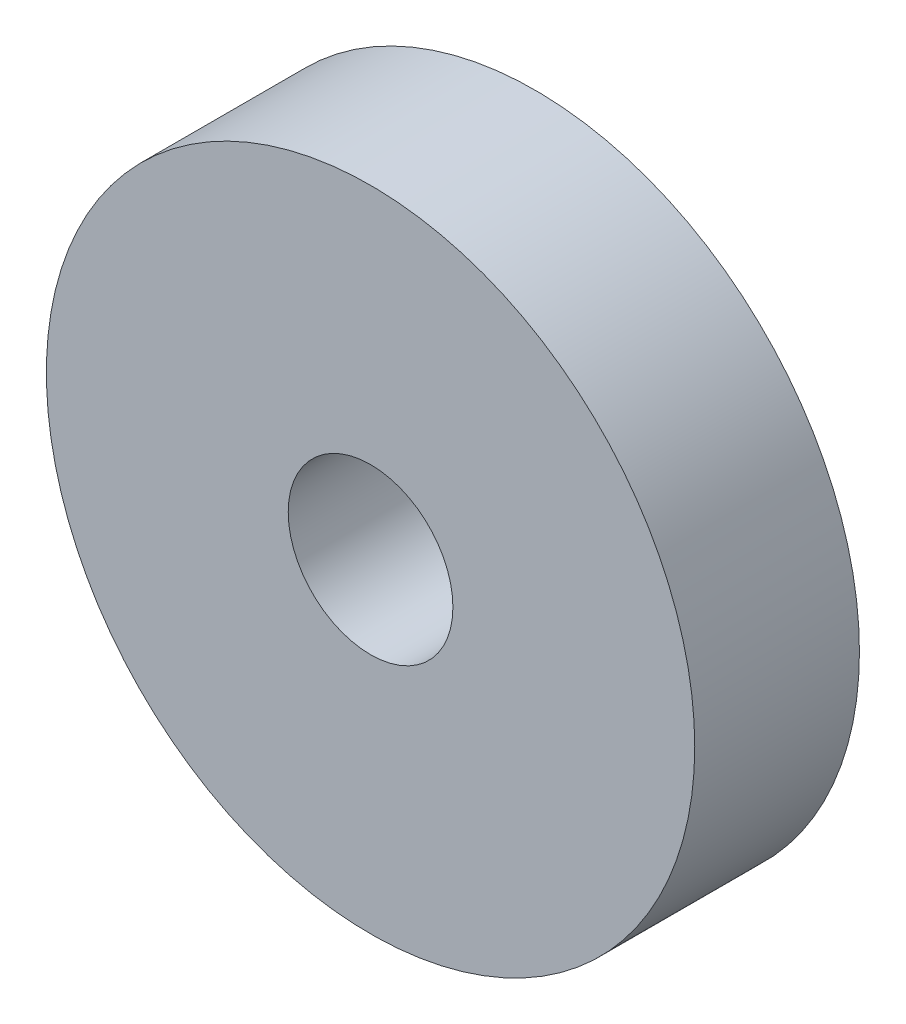
from build123d import *

# Parameters (mm, degrees)
SKETCH1_R                       = 12.5
BOSS_EXTRUDE1_DEPTH             = 6.35
F_1_4_0_25_DIAMETER_HOLE1_D     = 6.35
F_1_4_0_25_DIAMETER_HOLE1_DEPTH = 18
F_1_4_0_25_DIAMETER_HOLE1_TIP   = 1.907732465


with BuildPart() as part:
    # Sketch1 → Boss-Extrude1 (new body)
    with BuildSketch(Plane.XY):
        Circle(SKETCH1_R)
    extrude(amount=BOSS_EXTRUDE1_DEPTH)

    # 1/4 (0.25) Diameter Hole1
    with Locations(Plane(origin=(0, 0, 0), x_dir=(-1, 0, 0), z_dir=(0, 0, -1))):
        with Locations((0, 0)):
            Hole(F_1_4_0_25_DIAMETER_HOLE1_D / 2, depth=F_1_4_0_25_DIAMETER_HOLE1_DEPTH)
            with Locations((0, 0, -(F_1_4_0_25_DIAMETER_HOLE1_DEPTH + F_1_4_0_25_DIAMETER_HOLE1_TIP / 2))):  # 118° drill point
                Cone(0, F_1_4_0_25_DIAMETER_HOLE1_D / 2, F_1_4_0_25_DIAMETER_HOLE1_TIP, mode=Mode.SUBTRACT)


solid = part.part
